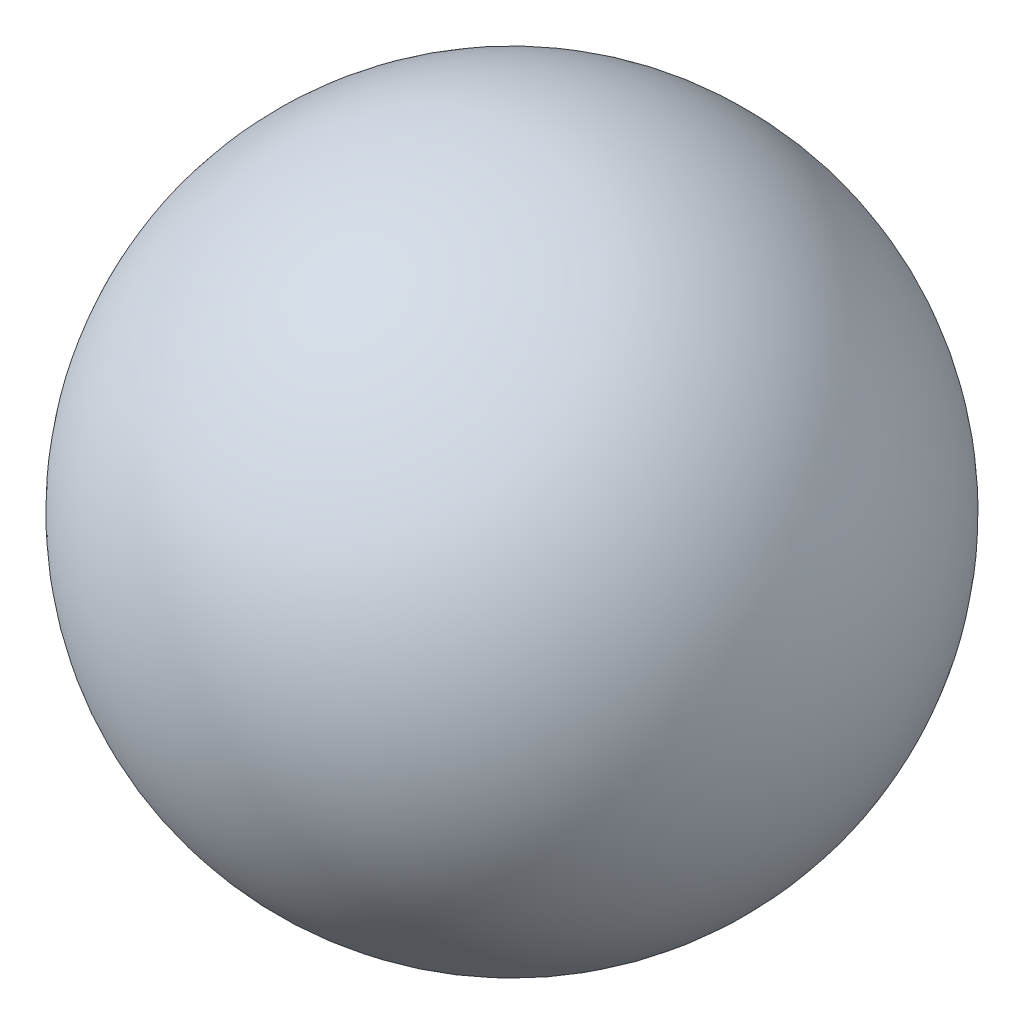
from build123d import *


with BuildPart() as part:
    # Sketch1 → Revolve1 (revolve)
    with BuildSketch(Plane.XY):
        with BuildLine():
            Line((-44.45, 0), (44.45, 0))
            ThreePointArc((44.45, 0), (0, 44.45), (-44.45, 0))
        make_face()
    revolve(axis=Axis((-44.45, 0, 0), (1, 0, 0)))


solid = part.part
